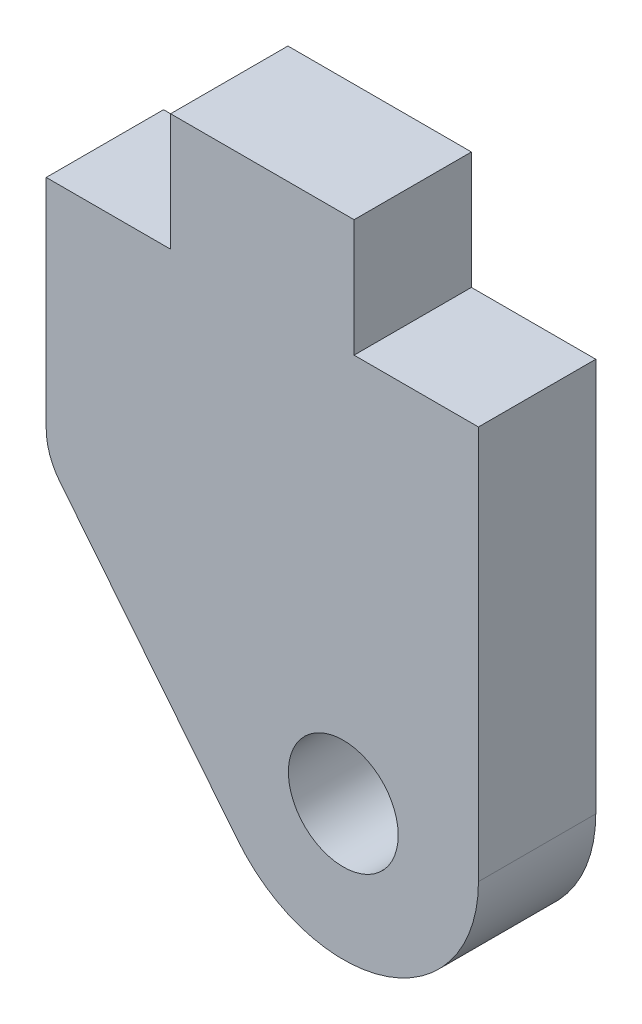
from build123d import *

# Parameters (mm, degrees)
SKETCH1_R           = 1.4859
BOSS_EXTRUDE1_DEPTH = 3.175


with BuildPart() as part:
    # Sketch1 → Boss-Extrude1 (new body)
    with BuildSketch(Plane.XY):
        with BuildLine():
            Line((-5.476150442, -1.381790583), (-0.66088404, -7.376813067))
            ThreePointArc((-0.66088404, -7.376813067), (3.40481365, -8.536580023), (5.84835, -5.08635))
            Line((5.84835, -5.08635), (5.84835, 5.56895))
            Line((5.84835, 5.56895), (2.48285, 5.56895))
            Line((2.48285, 5.56895), (2.48285, 8.74395))
            Line((2.48285, 8.74395), (-2.48285, 8.74395))
            Line((-2.48285, 8.74395), (-2.48285, 5.56895))
            Line((-2.48285, 5.56895), (-5.84835, 5.56895))
            Line((-5.84835, 5.56895), (-5.84835, -0.324042014))
            ThreePointArc((-5.84835, -0.324042014), (-5.752585393, -0.884703352), (-5.476150442, -1.381790583))
        make_face()
        with Locations((2.19075, -5.08635)):
            Circle(SKETCH1_R, mode=Mode.SUBTRACT)
    extrude(amount=BOSS_EXTRUDE1_DEPTH)


solid = part.part
